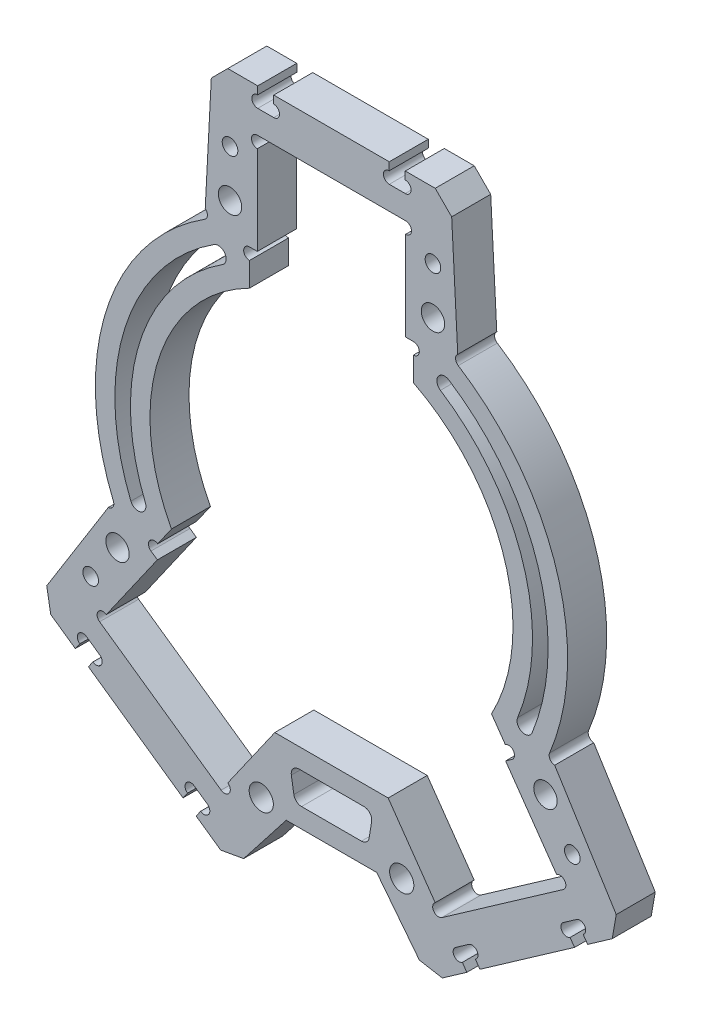
from build123d import *

# Parameters (mm, degrees)
EXTRUDE_1_DEPTH        = 2.5
SKETCH_2_W             = 2.05
SKETCH_2_H             = 5
CUT_EXTRUDE_1_DEPTH    = 6
SKETCH_3_R             = 0.75
CUT_EXTRUDE_2_DEPTH    = 6
CUT_EXTRUDE_3_DEPTH    = 6
SKETCH_5_R             = 0.75
CUT_EXTRUDE_4_DEPTH    = 6
CUT_EXTRUDE_6_DEPTH    = 6
SKETCH_8_R             = 0.75
CUT_EXTRUDE_7_DEPTH    = 6
CUT_EXTRUDE_8_DEPTH    = 6
CUT_EXTRUDE_9_DEPTH    = 6
CUT_EXTRUDE_10_DEPTH   = 6
FILLET_1_R             = 1
SKETCH_12_R            = 1.5
SKETCH_12_R_2          = 1
CUT_EXTRUDE_11_DEPTH   = 6
CHAMFER_1_SIZE2        = 2.113509005
CHAMFER_1_SIZE         = 2
CHAMFER_1_EDGE_2_SIZE2 = 2.113509005
CHAMFER_1_EDGE_2_SIZE  = 2
CHAMFER_1_EDGE_3_SIZE2 = 2
CHAMFER_1_EDGE_3_SIZE  = 2.113509005
CHAMFER_1_EDGE_4_SIZE2 = 2.113509005
CHAMFER_1_EDGE_4_SIZE  = 2
CHAMFER_1_EDGE_5_SIZE2 = 2
CHAMFER_1_EDGE_5_SIZE  = 2.113509005
CHAMFER_1_EDGE_6_SIZE2 = 2.113509005
CHAMFER_1_EDGE_6_SIZE  = 2
SKETCH_13_R            = 1.55
CUT_EXTRUDE_12_DEPTH   = 6


with BuildPart() as part:
    # 草图1 → 凸台-拉伸1 (new body, symmetric)
    with BuildSketch(Plane.XY):
        with BuildLine():
            Line((-15, 49.228571429), (15, 49.228571429))
            Line((15, 49.228571429), (16.242072966, 25.52840738))
            ThreePointArc((16.242072966, 25.52840738), (28.856904848, 9.098547149), (27.947220205, -11.595576762))
            Line((27.947220205, -11.595576762), (40.523629231, -31.722038378))
            Line((40.523629231, -31.722038378), (15.949067902, -48.929331468))
            Line((15.949067902, -48.929331468), (5.796130384, -35.93416405))
            Line((5.796130384, -35.93416405), (-5.796130384, -35.93416405))
            Line((-5.796130384, -35.93416405), (-15.949067902, -48.929331468))
            Line((-15.949067902, -48.929331468), (-40.523629231, -31.722038378))
            Line((-40.523629231, -31.722038378), (-27.947220205, -11.595576762))
            ThreePointArc((-27.947220205, -11.595576762), (-28.856904848, 9.098547149), (-16.242072966, 25.52840738))
            Line((-16.242072966, 25.52840738), (-15, 49.228571429))
        make_face()
        with BuildLine():
            Line((-9.5, 38.228571429), (9.5, 38.228571429))
            Line((9.5, 38.228571429), (9.5, 21.228571429))
            ThreePointArc((9.5, 21.228571429), (22.180886192, 6.993606553), (19.95815277, -11.940451538))
            Line((19.95815277, -11.940451538), (29.708952188, -25.866036291))
            Line((29.708952188, -25.866036291), (14.145063346, -36.763988581))
            Line((14.145063346, -36.763988581), (7.26214611, -26.93416405))
            Line((7.26214611, -26.93416405), (-7.26214611, -26.93416405))
            Line((-7.26214611, -26.93416405), (-14.145063346, -36.763988581))
            Line((-14.145063346, -36.763988581), (-29.708952188, -25.866036291))
            Line((-29.708952188, -25.866036291), (-19.95815277, -11.940451538))
            ThreePointArc((-19.95815277, -11.940451538), (-22.180886192, 6.993606553), (-9.5, 21.228571429))
            Line((-9.5, 21.228571429), (-9.5, 38.228571429))
        make_face(mode=Mode.SUBTRACT)
    extrude(amount=EXTRUDE_1_DEPTH, both=True)

    # 草图2 → 切除-拉伸1 (cut, through all)
    with BuildSketch(Plane.XY.offset(2.5)):
        with Locations((8.425, 43.728571429)):
            Rectangle(SKETCH_2_W, SKETCH_2_H)
        with Locations((-8.425, 43.728571429)):
            Rectangle(SKETCH_2_W, SKETCH_2_H)
        Polygon((34.256606076, -32.447931467), (31.388723894, -28.352171245), (29.709462204, -29.52800294), (32.577344385, -33.623763161), align=None)
        Polygon((15.906750257, -39.192765892), (17.586011948, -38.016934198), (20.45389413, -42.112694419), (18.774632439, -43.288526114), align=None)
        Polygon((-34.256606076, -32.447931467), (-32.577344385, -33.623763161), (-29.709462204, -29.52800294), (-31.388723894, -28.352171245), align=None)
        Polygon((-18.774632439, -43.288526114), (-15.906750257, -39.192765892), (-17.586011948, -38.016934198), (-20.45389413, -42.112694419), align=None)
    extrude(amount=-CUT_EXTRUDE_1_DEPTH, mode=Mode.SUBTRACT)

    # 草图3 → 切除-拉伸2 (cut, through all)
    with BuildSketch(Plane.XY.offset(2.5)):
        with Locations((-9.45, 45.478571429)):
            Circle(SKETCH_3_R)
        with Locations((-9.45, 41.978571429)):
            Circle(SKETCH_3_R)
        with Locations((-7.4, 41.978571429)):
            Circle(SKETCH_3_R)
        with Locations((-7.4, 45.478571429)):
            Circle(SKETCH_3_R)
        with Locations((7.4, 45.478571429)):
            Circle(SKETCH_3_R)
        with Locations((7.4, 41.978571429)):
            Circle(SKETCH_3_R)
        with Locations((9.45, 41.978571429)):
            Circle(SKETCH_3_R)
        with Locations((9.45, 45.478571429)):
            Circle(SKETCH_3_R)
        with Locations((-9.5, 37.478571429)):
            Circle(SKETCH_3_R)
        with Locations((9.5, 37.478571429)):
            Circle(SKETCH_3_R)
        with Locations((-29.27876986, -25.251672257)):
            Circle(SKETCH_3_R)
        with Locations((29.27876986, -25.251672257)):
            Circle(SKETCH_3_R)
        with Locations((-31.818906222, -28.966535279)):
            Circle(SKETCH_3_R)
        with Locations((-30.139644531, -30.142366973)):
            Circle(SKETCH_3_R)
        with Locations((-33.826423749, -31.833567434)):
            Circle(SKETCH_3_R)
        with Locations((-32.147162058, -33.009399128)):
            Circle(SKETCH_3_R)
        with Locations((-18.016194275, -38.631298231)):
            Circle(SKETCH_3_R)
        with Locations((-20.023711803, -41.498330386)):
            Circle(SKETCH_3_R)
        with Locations((-16.336932585, -39.807129926)):
            Circle(SKETCH_3_R)
        with Locations((-18.344450112, -42.674162081)):
            Circle(SKETCH_3_R)
        with Locations((16.336932585, -39.807129926)):
            Circle(SKETCH_3_R)
        with Locations((18.344450112, -42.674162081)):
            Circle(SKETCH_3_R)
        with Locations((18.016194275, -38.631298231)):
            Circle(SKETCH_3_R)
        with Locations((20.023711803, -41.498330386)):
            Circle(SKETCH_3_R)
        with Locations((30.139644531, -30.142366973)):
            Circle(SKETCH_3_R)
        with Locations((32.147162058, -33.009399128)):
            Circle(SKETCH_3_R)
        with Locations((33.826423749, -31.833567434)):
            Circle(SKETCH_3_R)
        with Locations((31.818906222, -28.966535279)):
            Circle(SKETCH_3_R)
        with Locations((-13.714881019, -36.149624548)):
            Circle(SKETCH_3_R)
        with Locations((13.714881019, -36.149624548)):
            Circle(SKETCH_3_R)
    extrude(amount=-CUT_EXTRUDE_2_DEPTH, mode=Mode.SUBTRACT)

    # 草图4 → 切除-拉伸3 (cut, through all)
    with BuildSketch(Plane(origin=(0, 0, -2.5), x_dir=(-1, 0, 0), z_dir=(0, 0, -1))):
        Polygon((-9.5, 25.328571429), (-10.5, 25.328571429), (-10.5, 20.752162415), (-9.5, 21.228571429), align=None)
        Polygon((-22.309816159, -15.298974919), (-23.128968203, -14.725398483), (-20.50404783, -10.976623684), (-19.95815277, -11.940451538), align=None)
        Polygon((20.50404783, -10.976623684), (19.95815277, -11.940451538), (22.309816159, -15.298974919), (23.128968203, -14.725398483), align=None)
        Polygon((10.5, 20.752162415), (9.5, 21.228571429), (9.5, 25.328571429), (10.5, 25.328571429), align=None)
    extrude(amount=-CUT_EXTRUDE_3_DEPTH, mode=Mode.SUBTRACT)

    # 草图5 → 切除-拉伸4 (cut, through all)
    with BuildSketch(Plane(origin=(0, 0, -2.5), x_dir=(-1, 0, 0), z_dir=(0, 0, -1))):
        with Locations((-10.5, 24.578571429)):
            Circle(SKETCH_5_R)
        with Locations((-22.698785876, -14.11103445)):
            Circle(SKETCH_5_R)
        with Locations((22.698785876, -14.11103445)):
            Circle(SKETCH_5_R)
        with Locations((10.5, 24.578571429)):
            Circle(SKETCH_5_R)
    extrude(amount=-CUT_EXTRUDE_4_DEPTH, mode=Mode.SUBTRACT)

    # 草图7 → 切除-拉伸6 (cut, through all)
    with BuildSketch(Plane.XY.offset(2.5)):
        with BuildLine():
            ThreePointArc((-15.041908084, 23.328287396), (-26.472612471, 8.346782651), (-25.702165708, -10.481730275))
            ThreePointArc((-25.702165708, -10.481730275), (-24.398584696, -11.030070084), (-23.850244887, -9.726489073))
            ThreePointArc((-23.850244887, -9.726489073), (-24.565178569, 7.745371052), (-13.958091916, 21.647411876))
            ThreePointArc((-13.958091916, 21.647411876), (-13.65956224, 23.02975772), (-15.041908084, 23.328287396))
        make_face()
        with BuildLine():
            ThreePointArc((15.041908084, 23.328287396), (26.472612471, 8.346782651), (25.702165708, -10.481730275))
            ThreePointArc((25.702165708, -10.481730275), (24.398584696, -11.030070084), (23.850244887, -9.726489073))
            ThreePointArc((23.850244887, -9.726489073), (24.565178569, 7.745371052), (13.958091916, 21.647411876))
            ThreePointArc((13.958091916, 21.647411876), (13.65956224, 23.02975772), (15.041908084, 23.328287396))
        make_face()
    extrude(amount=-CUT_EXTRUDE_6_DEPTH, mode=Mode.SUBTRACT)

    # 草图8 → 切除-拉伸7 (cut, through all)
    with BuildSketch(Plane.XY.offset(2.5)):
        with Locations((-16.644671765, 26.161190287)):
            Circle(SKETCH_8_R)
        with Locations((16.644671765, 26.161190287)):
            Circle(SKETCH_8_R)
        with Locations((-28.639959199, -11.883000989)):
            Circle(SKETCH_8_R)
        with Locations((28.639959199, -11.883000989)):
            Circle(SKETCH_8_R)
    extrude(amount=-CUT_EXTRUDE_7_DEPTH, mode=Mode.SUBTRACT)

    # 草图9 → 切除-拉伸8 (cut, through all)
    with BuildSketch(Plane.XY.offset(2.5)):
        Polygon((-15.288242786, 43.728571429), (15.288242786, 43.728571429), (15, 49.228571429), (-15, 49.228571429), align=None)
    extrude(amount=-CUT_EXTRUDE_8_DEPTH, mode=Mode.SUBTRACT)

    # 草图10 → 切除-拉伸9 (cut, through all)
    with BuildSketch(Plane.XY.offset(2.5)):
        Polygon((-37.605073499, -27.051372864), (-12.558282835, -44.589324495), (-15.949067902, -48.929331468), (-40.523629231, -31.722038378), align=None)
    cut_extrude_9 = extrude(amount=-CUT_EXTRUDE_9_DEPTH, mode=Mode.SUBTRACT)

    # 镜向1: 切除-拉伸9 across plane
    add(cut_extrude_9.mirror(Plane(origin=(0, 0, 0), x_dir=(0, 0, 1), z_dir=(1, 0, 0))), mode=Mode.SUBTRACT)

    # 草图11 → 切除-拉伸10 (cut, through all)
    with BuildSketch(Plane.XY.offset(2.5)):
        Polygon((-5.335149781, -29.43416405), (-4.683587236, -33.43416405), (4.683587236, -33.43416405), (5.335149781, -29.43416405), align=None)
    extrude(amount=-CUT_EXTRUDE_10_DEPTH, mode=Mode.SUBTRACT)

    # 圆角1
    fillet_1_edges = [part.edges().sort_by_distance(p)[0] for p in [
        (-5.335149781, -29.43416405, 0),
        (5.335149781, -29.43416405, 0),
        (4.683587236, -33.43416405, 0),
        (-4.683587236, -33.43416405, 0),
    ]]
    fillet(fillet_1_edges, radius=FILLET_1_R)

    # 草图12 → 切除-拉伸11 (cut, through all)
    with BuildSketch(Plane.XY.offset(2.5)):
        with Locations((-13, 29.228571429)):
            Circle(SKETCH_12_R)
        with Locations((-27.413796415, -16.486150365)):
            Circle(SKETCH_12_R)
        with Locations((13, 29.228571429)):
            Circle(SKETCH_12_R)
        with Locations((27.413796415, -16.486150365)):
            Circle(SKETCH_12_R)
        with Locations((-13, 35.228571429)):
            Circle(SKETCH_12_R_2)
        with Locations((-30.855255033, -21.401062631)):
            Circle(SKETCH_12_R_2)
        with Locations((30.855255033, -21.401062631)):
            Circle(SKETCH_12_R_2)
        with Locations((13, 35.228571429)):
            Circle(SKETCH_12_R_2)
    extrude(amount=-CUT_EXTRUDE_11_DEPTH, mode=Mode.SUBTRACT)

    # 倒角1
    chamfer_1_edges = [part.edges().sort_by_distance(p)[0] for p in [
        (15.288242786, 43.728571429, 0),
    ]]
    chamfer(chamfer_1_edges, length=CHAMFER_1_SIZE, length2=CHAMFER_1_SIZE2)

    # 倒角1 edge 2
    chamfer_1_edge_2_edges = [part.edges().sort_by_distance(p)[0] for p in [
        (-15.288242786, 43.728571429, 0),
    ]]
    chamfer(chamfer_1_edge_2_edges, length=CHAMFER_1_EDGE_2_SIZE, length2=CHAMFER_1_EDGE_2_SIZE2)

    # 倒角1 edge 3
    chamfer_1_edge_3_edges = [part.edges().sort_by_distance(p)[0] for p in [
        (-37.605073499, -27.051372864, 0),
    ]]
    chamfer(chamfer_1_edge_3_edges, length=CHAMFER_1_EDGE_3_SIZE, length2=CHAMFER_1_EDGE_3_SIZE2)

    # 倒角1 edge 4
    chamfer_1_edge_4_edges = [part.edges().sort_by_distance(p)[0] for p in [
        (-12.558282835, -44.589324495, 0),
    ]]
    chamfer(chamfer_1_edge_4_edges, length=CHAMFER_1_EDGE_4_SIZE, length2=CHAMFER_1_EDGE_4_SIZE2)

    # 倒角1 edge 5
    chamfer_1_edge_5_edges = [part.edges().sort_by_distance(p)[0] for p in [
        (12.558282835, -44.589324495, 0),
    ]]
    chamfer(chamfer_1_edge_5_edges, length=CHAMFER_1_EDGE_5_SIZE, length2=CHAMFER_1_EDGE_5_SIZE2)

    # 倒角1 edge 6
    chamfer_1_edge_6_edges = [part.edges().sort_by_distance(p)[0] for p in [
        (37.605073499, -27.051372864, 0),
    ]]
    chamfer(chamfer_1_edge_6_edges, length=CHAMFER_1_EDGE_6_SIZE, length2=CHAMFER_1_EDGE_6_SIZE2)

    # 草图13 → 切除-拉伸12 (cut, through all)
    with BuildSketch(Plane(origin=(0, 0, -2.5), x_dir=(-1, 0, 0), z_dir=(0, 0, -1))):
        with Locations((-9, -35)):
            Circle(SKETCH_13_R)
        with Locations((9, -35)):
            Circle(SKETCH_13_R)
    extrude(amount=-CUT_EXTRUDE_12_DEPTH, mode=Mode.SUBTRACT)


solid = part.part
